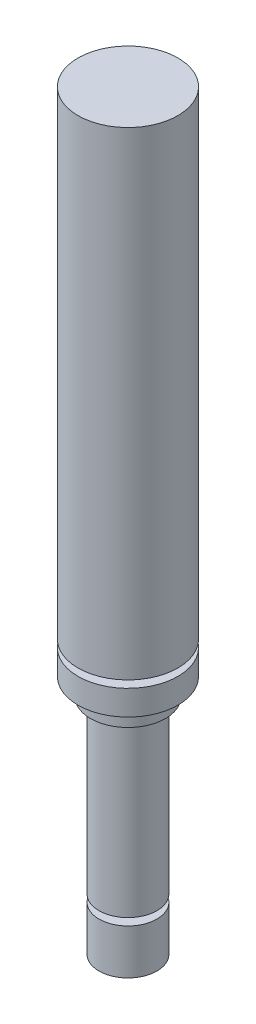
from build123d import *


with BuildPart() as part:
    # Sketch1 → Revolve1 (revolve)
    with BuildSketch(Plane.XY):
        Polygon((0, 0), (2, 0), (2, 3.111660195), (1.299327849, 3.111660195), (1.299327849, 3.611660195), (2, 3.611660195), (2, 15.4), (2.5875, 15.4), (2.5875, 16.632142857), (3.45, 16.632142857), (3.45, 18.354934716), (2.5875, 18.354934716), (2.5875, 18.854934716), (3.45, 18.854934716), (3.45, 51.9), (0, 51.9), align=None)
    revolve(axis=Axis((0, 8.4525, 0), (0, -1, 0)))


solid = part.part
